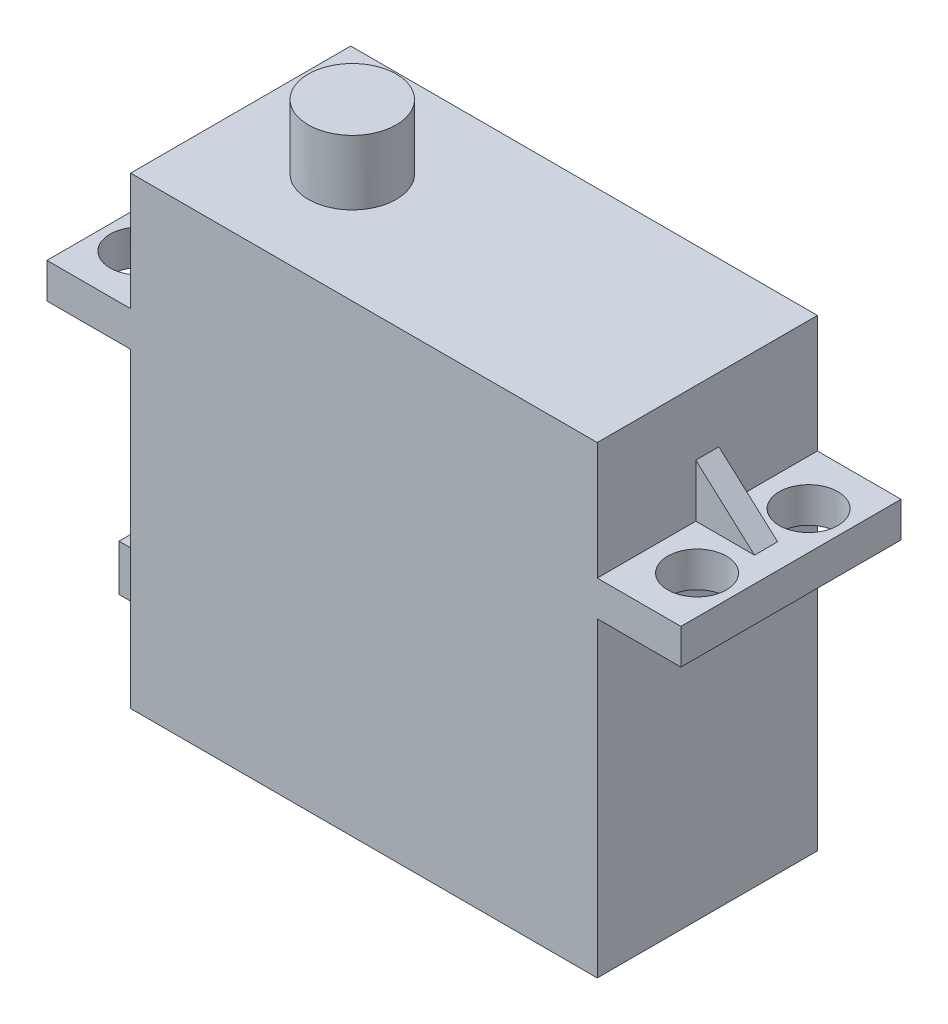
from build123d import *

# Parameters (mm, degrees)
SKETCH1_W               = 40.386
SKETCH1_H               = 40.132
BOSS_EXTRUDE1_DEPTH     = 19.05
SKETCH2_W               = 7.239
SKETCH2_H               = 3.048
BOSS_EXTRUDE2_DEPTH     = 19.05
SKETCH3_R               = 2.54
CUT_EXTRUDE1_DEPTH      = 11.16
CUT_EXTRUDE1_DEPTH_BACK = 30.972
SKETCH4_R               = 3.81
BOSS_EXTRUDE3_DEPTH     = 5.588
SKETCH5_W               = 9.05
SKETCH5_H               = 4
BOSS_EXTRUDE4_DEPTH     = 6
BOSS_EXTRUDE5_DEPTH     = 1


with BuildPart() as part:
    # Sketch1 → Boss-Extrude1 (new body)
    with BuildSketch(Plane.XY):
        with Locations((20.193, 20.066)):
            Rectangle(SKETCH1_W, SKETCH1_H)
    extrude(amount=BOSS_EXTRUDE1_DEPTH)

    # Sketch2 → Boss-Extrude2 (add)
    with BuildSketch(Plane.XY.offset(19.05)):
        with Locations((-3.6195, 28.448)):
            Rectangle(SKETCH2_W, SKETCH2_H)
        with Locations((44.0055, 28.448)):
            Rectangle(SKETCH2_W, SKETCH2_H)
    extrude(amount=-BOSS_EXTRUDE2_DEPTH)

    # Sketch3 → Cut-Extrude1 (cut, two sides)
    with BuildSketch(Plane(origin=(0, 29.972, 0), x_dir=(1, 0, 0), z_dir=(0, 1, 0))) as cut_extrude1_sk:
        with Locations((-3.937, -14.351)):
            Circle(SKETCH3_R)
        with Locations((-3.937, -4.699)):
            Circle(SKETCH3_R)
        with Locations((44.323, -14.351)):
            Circle(SKETCH3_R)
        with Locations((44.323, -4.699)):
            Circle(SKETCH3_R)
    extrude(amount=CUT_EXTRUDE1_DEPTH, mode=Mode.SUBTRACT)
    extrude(cut_extrude1_sk.sketch, amount=-CUT_EXTRUDE1_DEPTH_BACK, mode=Mode.SUBTRACT)

    # Sketch4 → Boss-Extrude3 (add)
    with BuildSketch(Plane(origin=(0, 40.132, 0), x_dir=(1, 0, 0), z_dir=(0, 1, 0))):
        with Locations((9.66, -9.525)):
            Circle(SKETCH4_R)
    extrude(amount=BOSS_EXTRUDE3_DEPTH)

    # Sketch5 → Boss-Extrude4 (add)
    with BuildSketch(Plane.ZY):
        with Locations((9.525, 5.048)):
            Rectangle(SKETCH5_W, SKETCH5_H)
    extrude(amount=BOSS_EXTRUDE4_DEPTH)

    # Sketch7 → Boss-Extrude5 (add, symmetric)
    with BuildSketch(Plane.XY.offset(9.525)):
        Polygon((-6.35, 29.972), (0, 32.512), (0, 29.972), align=None)
        Polygon((45.466, 29.972), (40.386, 34.55105012), (40.386, 29.972), align=None)
    extrude(amount=BOSS_EXTRUDE5_DEPTH, both=True)


solid = part.part
